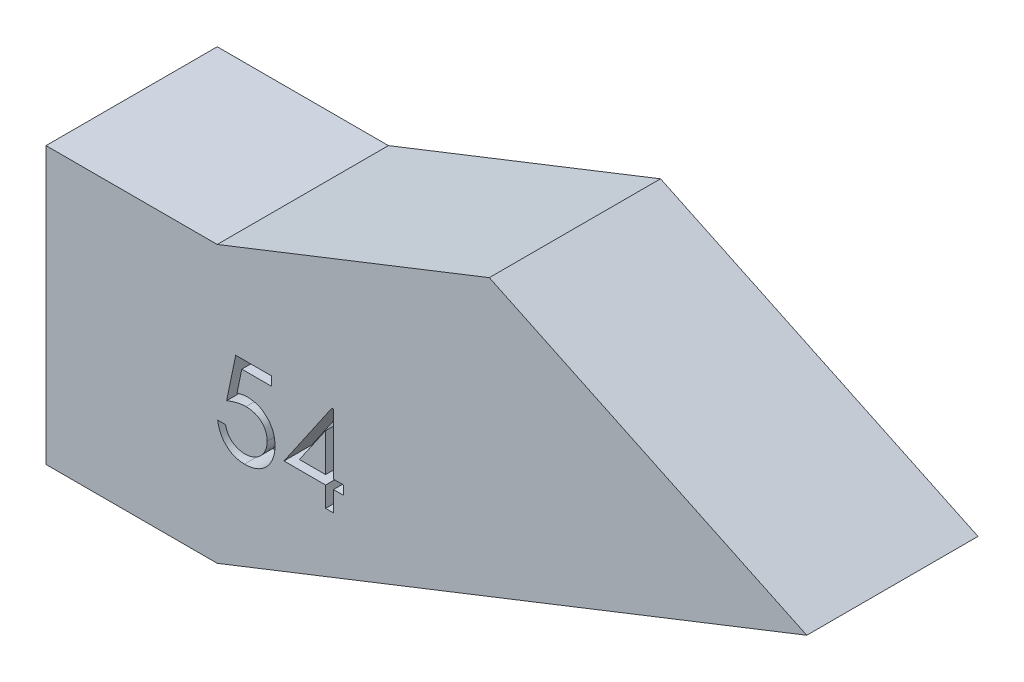
from build123d import *

# Parameters (mm, degrees)
BOSS_EXTRUDE1_DEPTH = 6.2
CUT_EXTRUDE1_DEPTH  = 1


with BuildPart() as part:
    # Sketch1 → Boss-Extrude1 (new body)
    with BuildSketch(Plane(origin=(0, 0, 0), x_dir=(-1, 0, 0), z_dir=(0, 0, 1))):
        Polygon((-81.198418694, 94.917906577), (-102.547087364, 86.499465833), (-91.051660388, 81.032468444), (-81.198418694, 84.917906577), (-74.998418694, 84.917906577), (-74.998418694, 94.917906577), align=None)
    extrude(amount=BOSS_EXTRUDE1_DEPTH)

    # Sketch2 → Cut-Extrude1 (cut)
    with BuildSketch(Plane.XY.offset(6.2)):
        with BuildLine():
            Line((83.169030289, -88.057134239), (83.169030289, -88.382775265))
            Line((83.169030289, -88.382775265), (82.089072356, -88.382775265))
            Line((82.089072356, -88.382775265), (81.917983614, -89.217866411))
            add(Edge.make_bspline(
                [(81.917983614, -89.217866411), (81.951598586, -89.208586093), (82.016722277, -89.190606945), (82.112843008, -89.170644567), (82.204094507, -89.158610914), (82.263308593, -89.156967797), (82.291961979, -89.156172701)],
                knots=[0, 0, 0, 0, 0.000104595, 0.000202637, 0.000294305, 0.000380252, 0.000380252, 0.000380252, 0.000380252], degree=3))
            add(Edge.make_bspline(
                [(82.291961979, -89.156172701), (82.327416515, -89.156940085), (82.397128989, -89.158448955), (82.499127177, -89.172937704), (82.596493445, -89.195743198), (82.689024166, -89.227602529), (82.776890523, -89.268342072), (82.859284096, -89.319232733), (82.937441632, -89.378680826), (83.009960985, -89.447029515), (83.075750893, -89.522251268), (83.133595755, -89.603130193), (83.182728962, -89.688880287), (83.222244789, -89.780320839), (83.25379915, -89.876440928), (83.274801317, -89.978251914), (83.288786474, -90.084794137), (83.290348924, -90.157641854), (83.291145673, -90.194789488)],
                knots=[0, 0, 0, 0, 0.000106308, 0.000209029, 0.000308378, 0.000405929, 0.000502102, 0.000598312, 0.00069588, 0.000796219, 0.000896736, 0.000995218, 0.001094066, 0.001192613, 0.001293582, 0.001396995, 0.001504047, 0.001615439, 0.001615439, 0.001615439, 0.001615439], degree=3))
            add(Edge.make_bspline(
                [(83.291145673, -90.194789488), (83.290542355, -90.220663216), (83.289343872, -90.272061012), (83.283249153, -90.348391823), (83.271514611, -90.423106678), (83.255759604, -90.496215491), (83.23531041, -90.56757985), (83.21055534, -90.637404022), (83.180260372, -90.705253415), (83.147030482, -90.771770023), (83.109614034, -90.835450098), (83.068086388, -90.895003107), (83.024211978, -90.95132242), (82.977003007, -91.00380402), (82.926020676, -91.052103044), (82.87188242, -91.096506128), (82.815020239, -91.137764191), (82.754554412, -91.174202483), (82.691832303, -91.207733164), (82.625948134, -91.235240945), (82.558401642, -91.259834067), (82.488220647, -91.279436995), (82.415564117, -91.294797241), (82.340312285, -91.305229929), (82.26285982, -91.312828554), (82.210358916, -91.313304221), (82.183838983, -91.313544496)],
                knots=[0, 0, 0, 0, 7.7636e-05, 0.000154223, 0.000229512, 0.000304362, 0.000378447, 0.000452077, 0.000526407, 0.000601214, 0.00067506, 0.000747747, 0.00081887, 0.000889121, 0.000959302, 0.001029336, 0.001099058, 0.00116985, 0.001240974, 0.00131221, 0.00138383, 0.001456517, 0.001530612, 0.001606437, 0.001684346, 0.001763871, 0.001763871, 0.001763871, 0.001763871], degree=3))
            add(Edge.make_bspline(
                [(82.183838983, -91.313544496), (82.152203119, -91.312917807), (82.089963294, -91.311684871), (81.998776779, -91.298786674), (81.911042816, -91.280313692), (81.827467652, -91.252522219), (81.747302292, -91.217699459), (81.671625969, -91.17368836), (81.598505015, -91.123814459), (81.530911953, -91.06495871), (81.468177479, -91.000628056), (81.412019432, -90.930816481), (81.362005401, -90.856676202), (81.318936302, -90.777847162), (81.282198811, -90.694536495), (81.253338072, -90.606432058), (81.230044136, -90.513994197), (81.220189462, -90.450354942), (81.215184135, -90.418031675)],
                knots=[0, 0, 0, 0, 9.4843e-05, 0.000186593, 0.000275792, 0.000363484, 0.000450342, 0.000537514, 0.000625728, 0.000715478, 0.000805885, 0.000894984, 0.00098389, 0.001073836, 0.001164117, 0.001256635, 0.001351658, 0.001449737, 0.001449737, 0.001449737, 0.001449737], degree=3))
            Line((81.215184135, -90.418031675), (81.500120032, -90.418031675))
            add(Edge.make_bspline(
                [(81.500120032, -90.418031675), (81.507130938, -90.448308886), (81.520606288, -90.506503365), (81.55018436, -90.588265368), (81.586348404, -90.661126378), (81.62935092, -90.726050214), (81.680649876, -90.78266409), (81.739187287, -90.833116711), (81.804817007, -90.878632721), (81.877745151, -90.916571945), (81.95468273, -90.9489286), (82.035207271, -90.970474781), (82.117126214, -90.985624876), (82.172533021, -90.987141402), (82.200375441, -90.98790347)],
                knots=[0, 0, 0, 0, 9.3172e-05, 0.000179081, 0.000260145, 0.000336703, 0.000411917, 0.000488562, 0.000568128, 0.000650923, 0.00073478, 0.000817953, 0.000900557, 0.000983994, 0.000983994, 0.000983994, 0.000983994], degree=3))
            add(Edge.make_bspline(
                [(82.200375441, -90.98790347), (82.22755203, -90.987158907), (82.281062956, -90.985692857), (82.359813285, -90.974408896), (82.435843535, -90.957030242), (82.508403495, -90.931022588), (82.578762891, -90.899413451), (82.645141954, -90.858850489), (82.709460993, -90.812168901), (82.7697208, -90.758686815), (82.824910872, -90.699750021), (82.873675353, -90.636724099), (82.91429441, -90.569489531), (82.948524637, -90.499210314), (82.974517273, -90.425116194), (82.993060163, -90.347554414), (83.003948652, -90.266333396), (83.005446508, -90.210934808), (83.006209776, -90.182705153)],
                knots=[0, 0, 0, 0, 8.15e-05, 0.000160473, 0.000238226, 0.000315066, 0.000391338, 0.000469218, 0.000547964, 0.000629516, 0.000710512, 0.000789892, 0.000868102, 0.000945761, 0.001024012, 0.00110315, 0.001184644, 0.001269321, 0.001269321, 0.001269321, 0.001269321], degree=3))
            add(Edge.make_bspline(
                [(83.006209776, -90.182705153), (83.005612441, -90.157236435), (83.004443243, -90.107385045), (82.994890511, -90.034451479), (82.978274401, -89.965442362), (82.955211309, -89.900024449), (82.925929185, -89.838136041), (82.890145744, -89.779713265), (82.847189447, -89.725526145), (82.798120377, -89.675549328), (82.744364868, -89.629425763), (82.684998045, -89.590106485), (82.621262254, -89.557028502), (82.553925403, -89.528482533), (82.481385817, -89.507980428), (82.405080014, -89.492588132), (82.324184001, -89.483684196), (82.268874876, -89.482448768), (82.240444552, -89.481813727)],
                knots=[0, 0, 0, 0, 7.6388e-05, 0.000149519, 0.000220172, 0.000288967, 0.000357247, 0.000425206, 0.000494043, 0.000564207, 0.000635056, 0.000706145, 0.000777268, 0.000850264, 0.000925136, 0.001002969, 0.001083601, 0.001168886, 0.001168886, 0.001168886, 0.001168886], degree=3))
            add(Edge.make_bspline(
                [(82.240444552, -89.481813727), (82.215834738, -89.482340406), (82.165021715, -89.483427864), (82.087077437, -89.491434758), (82.005169945, -89.504351832), (81.919613224, -89.522119357), (81.830150335, -89.545370405), (81.736970071, -89.573232845), (81.639876515, -89.606544944), (81.574455436, -89.631702023), (81.540825161, -89.644634239)],
                knots=[0, 0, 0, 0, 7.3822e-05, 0.000152423, 0.000234822, 0.000322511, 0.00041445, 0.000512043, 0.000614219, 0.000722306, 0.000722306, 0.000722306, 0.000722306], degree=3))
            Line((81.540825161, -89.644634239), (81.866466186, -88.057134239))
            Line((81.866466186, -88.057134239), (83.169030289, -88.057134239))
        make_face()
        Polygon((85.349934736, -87.975723983), (85.40781234, -87.975723983), (85.40781234, -90.173800906), (85.774158494, -90.173800906), (85.774158494, -90.499441932), (85.40781234, -90.499441932), (85.40781234, -91.232134239), (85.122876443, -91.232134239), (85.122876443, -90.499441932), (83.616786699, -90.499441932), align=None)
        Polygon((85.122876443, -90.173800906), (85.122876443, -88.794914688), (84.176482212, -90.173800906), align=None, mode=Mode.SUBTRACT)
    extrude(amount=-CUT_EXTRUDE1_DEPTH, mode=Mode.SUBTRACT)


solid = part.part
